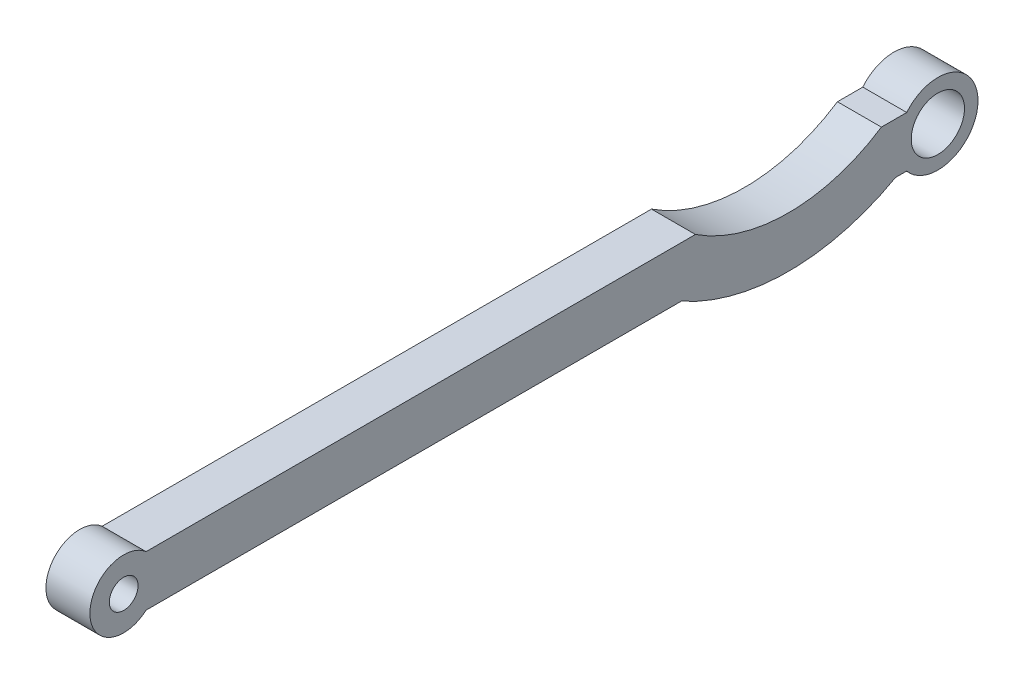
from build123d import *

# Parameters (mm, degrees)
SKETCH_1_R      = 3.15
SKETCH_1_R_2    = 1.7
EXTRUDE_1_DEPTH = 5.2


with BuildPart() as part:
    # Эскиз1 → Бобышка-Вытянуть1 (new body)
    with BuildSketch(Plane(origin=(0, 0, 0), x_dir=(0, 0, -1), z_dir=(1, 0, 0))):
        with BuildLine():
            Line((35.228149956, 3), (38.228149956, 3))
            ThreePointArc((38.228149956, 3), (46.660879922, 0), (38.228149956, -3))
            Line((38.228149956, -3), (36.899396262, -3))
            ThreePointArc((36.899396262, -3), (24.228149956, -6.296706912), (11.55690365, -3))
            Line((11.55690365, -3), (-51.771850044, -3))
            ThreePointArc((-51.771850044, -3), (-58.417601355, 0), (-51.771850044, 3))
            Line((-51.771850044, 3), (13.228149956, 3))
            ThreePointArc((13.228149956, 3), (24.228149956, -0.296706912), (35.228149956, 3))
        make_face()
        with Locations((41.910879922, 0)):
            Circle(SKETCH_1_R, mode=Mode.SUBTRACT)
        with Locations((-54.417601355, 0)):
            Circle(SKETCH_1_R_2, mode=Mode.SUBTRACT)
    extrude(amount=EXTRUDE_1_DEPTH)


solid = part.part
